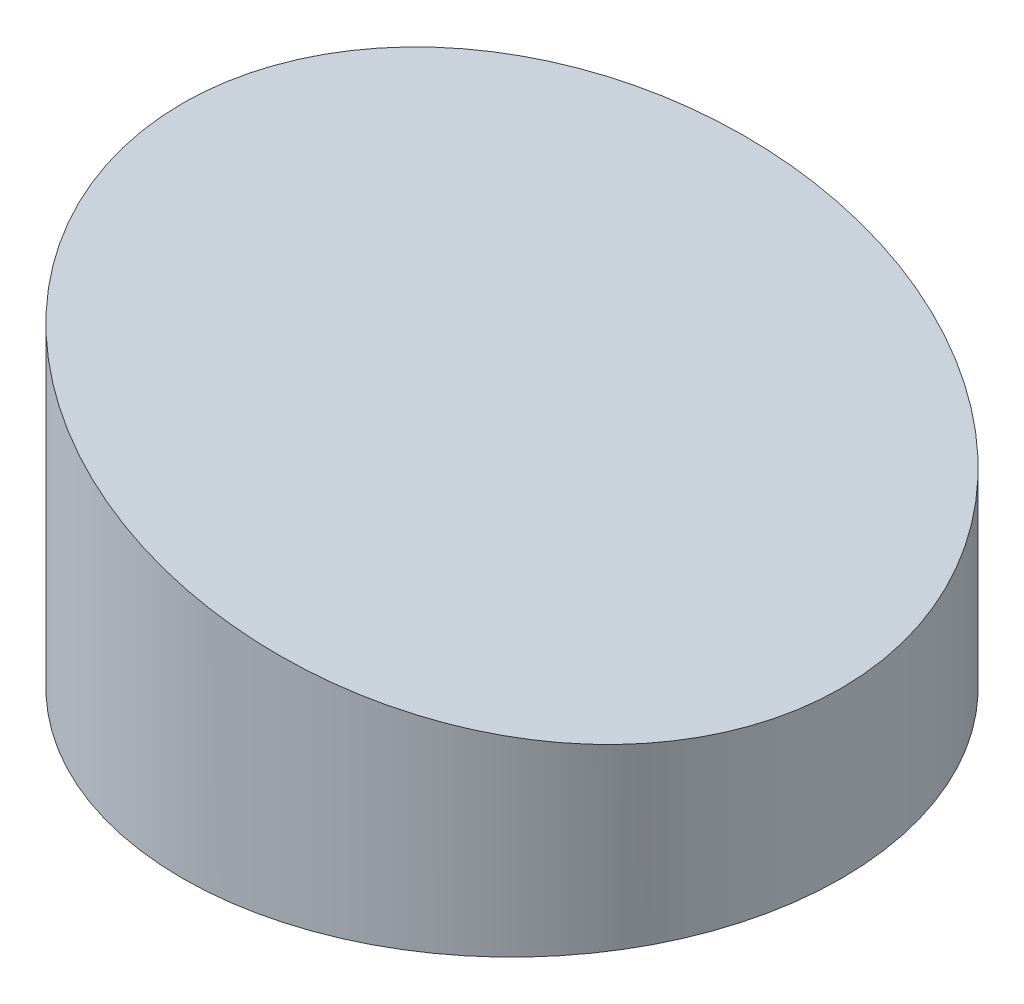
from build123d import *

# Parameters (mm, degrees)
SKETCH1_R               = 12.7
BOSS_EXTRUDE1_DEPTH     = 13.16
CUT_EXTRUDE4_DEPTH      = 13.7
CUT_EXTRUDE4_DEPTH_BACK = 13.7
SKETCH4_R               = 1.595
CUT_EXTRUDE9_DEPTH      = 4.32


with BuildPart() as part:
    # Sketch1 → Boss-Extrude1 (new body)
    with BuildSketch(Plane(origin=(0, 0, 0), x_dir=(1, 0, 0), z_dir=(0, 1, 0))):
        Circle(SKETCH1_R)
    extrude(amount=BOSS_EXTRUDE1_DEPTH)

    # Sketch2 → Cut-Extrude4 (cut, two sides)
    with BuildSketch(Plane.XY) as cut_extrude4_sk:
        Polygon((-77.620622605, 30.565883462), (-12.7, 13.16), (12.7, 6.35), (77.620622605, -11.055883462), (112.43238953, 118.785361749), (-42.808855681, 160.407128673), align=None)
    extrude(amount=CUT_EXTRUDE4_DEPTH, mode=Mode.SUBTRACT)
    extrude(cut_extrude4_sk.sketch, amount=-CUT_EXTRUDE4_DEPTH_BACK, mode=Mode.SUBTRACT)

    # Sketch4 → Cut-Extrude9 (cut)
    with BuildSketch(Plane(origin=(0, 0, 0), x_dir=(1, 0, 0), z_dir=(0, 1, 0))):
        with Locations((-9.525, 0)):
            Circle(SKETCH4_R)
        with Locations((0.005, 0)):
            Circle(SKETCH4_R)
        with Locations((9.535, 0)):
            Circle(SKETCH4_R)
        with Locations((4.7625, 8.248891971)):
            Circle(SKETCH4_R)
        with Locations((4.7625, -8.248891971)):
            Circle(SKETCH4_R)
    extrude(amount=CUT_EXTRUDE9_DEPTH, mode=Mode.SUBTRACT)


solid = part.part
